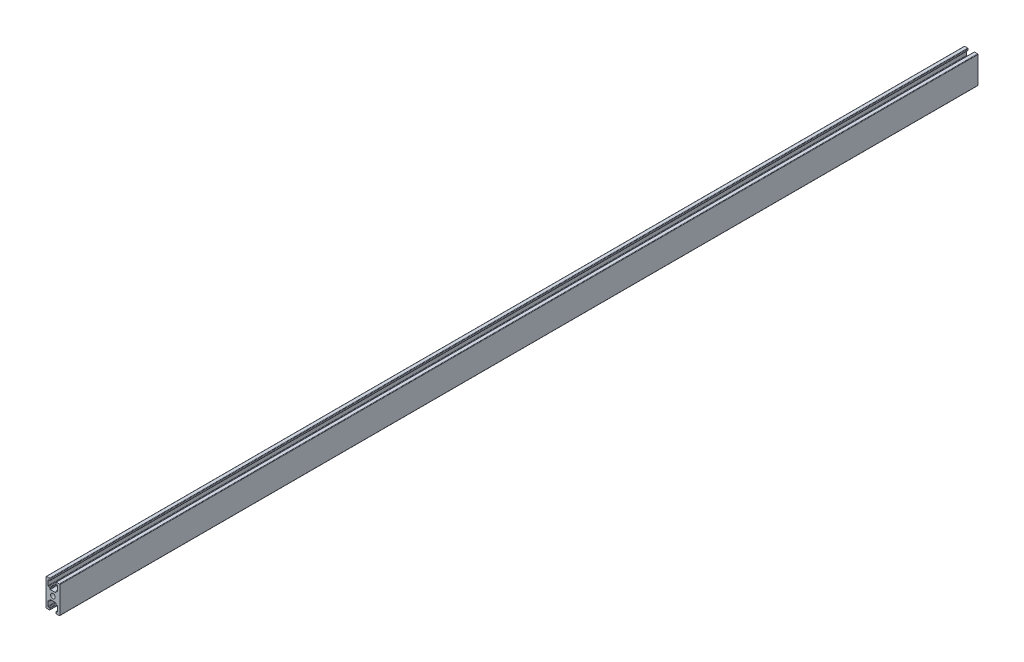
from build123d import *

# Parameters (mm, degrees)
SKETCH_2_R      = 2.5
EXTRUDE_1_DEPTH = 1000


with BuildPart() as part:
    # Эскиз2 → Бобышка-Вытянуть1 (new body)
    with BuildSketch(Plane.XY):
        with BuildLine():
            Line((-5.25, 15), (-7, 15))
            ThreePointArc((-7, 15), (-7.353553391, 14.853553391), (-7.5, 14.5))
            Line((-7.5, 14.5), (-7.5, -14.5))
            ThreePointArc((-7.5, -14.5), (-7.353553391, -14.853553391), (-7, -15))
            Line((-7, -15), (-5.25, -15))
            Line((-5.25, -15), (-3.75, -15))
            ThreePointArc((-3.75, -15), (-3.396446609, -14.853553391), (-3.25, -14.5))
            Line((-3.25, -14.5), (-3.25, -13.2))
            ThreePointArc((-3.25, -13.2), (-3.396446609, -12.846446609), (-3.75, -12.7))
            Line((-3.75, -12.7), (-4.75, -12.7))
            ThreePointArc((-4.75, -12.7), (-5.103553391, -12.553553391), (-5.25, -12.2))
            Line((-5.25, -12.2), (-5.25, -7.2))
            ThreePointArc((-5.25, -7.2), (-5.103553391, -6.846446609), (-4.75, -6.7))
            Line((-4.75, -6.7), (-3.75, -6.7))
            ThreePointArc((-3.75, -6.7), (-3.396446609, -6.553553391), (-3.25, -6.2))
            Line((-3.25, -6.2), (-3.25, -5.2))
            ThreePointArc((-3.25, -5.2), (-3.103553391, -4.846446609), (-2.75, -4.7))
            Line((-2.75, -4.7), (2.75, -4.7))
            ThreePointArc((2.75, -4.7), (3.103553391, -4.846446609), (3.25, -5.2))
            Line((3.25, -5.2), (3.25, -6.2))
            ThreePointArc((3.25, -6.2), (3.396446609, -6.553553391), (3.75, -6.7))
            Line((3.75, -6.7), (4.75, -6.7))
            ThreePointArc((4.75, -6.7), (5.103553391, -6.846446609), (5.25, -7.2))
            Line((5.25, -7.2), (5.25, -12.2))
            ThreePointArc((5.25, -12.2), (5.103553391, -12.553553391), (4.75, -12.7))
            Line((4.75, -12.7), (3.75, -12.7))
            ThreePointArc((3.75, -12.7), (3.396446609, -12.846446609), (3.25, -13.2))
            Line((3.25, -13.2), (3.25, -14.5))
            ThreePointArc((3.25, -14.5), (3.396446609, -14.853553391), (3.75, -15))
            Line((3.75, -15), (5.25, -15))
            Line((5.25, -15), (7, -15))
            ThreePointArc((7, -15), (7.353553391, -14.853553391), (7.5, -14.5))
            Line((7.5, -14.5), (7.5, 14.5))
            ThreePointArc((7.5, 14.5), (7.353553391, 14.853553391), (7, 15))
            Line((7, 15), (5.25, 15))
            Line((5.25, 15), (3.75, 15))
            ThreePointArc((3.75, 15), (3.396446609, 14.853553391), (3.25, 14.5))
            Line((3.25, 14.5), (3.25, 13.2))
            ThreePointArc((3.25, 13.2), (3.396446609, 12.846446609), (3.75, 12.7))
            Line((3.75, 12.7), (4.75, 12.7))
            ThreePointArc((4.75, 12.7), (5.103553391, 12.553553391), (5.25, 12.2))
            Line((5.25, 12.2), (5.25, 7.2))
            ThreePointArc((5.25, 7.2), (5.103553391, 6.846446609), (4.75, 6.7))
            Line((4.75, 6.7), (3.75, 6.7))
            ThreePointArc((3.75, 6.7), (3.396446609, 6.553553391), (3.25, 6.2))
            Line((3.25, 6.2), (3.25, 5.2))
            ThreePointArc((3.25, 5.2), (3.103553391, 4.846446609), (2.75, 4.7))
            Line((2.75, 4.7), (-2.75, 4.7))
            ThreePointArc((-2.75, 4.7), (-3.103553391, 4.846446609), (-3.25, 5.2))
            Line((-3.25, 5.2), (-3.25, 6.2))
            ThreePointArc((-3.25, 6.2), (-3.396446609, 6.553553391), (-3.75, 6.7))
            Line((-3.75, 6.7), (-4.75, 6.7))
            ThreePointArc((-4.75, 6.7), (-5.103553391, 6.846446609), (-5.25, 7.2))
            Line((-5.25, 7.2), (-5.25, 12.2))
            ThreePointArc((-5.25, 12.2), (-5.103553391, 12.553553391), (-4.75, 12.7))
            Line((-4.75, 12.7), (-3.75, 12.7))
            ThreePointArc((-3.75, 12.7), (-3.396446609, 12.846446609), (-3.25, 13.2))
            Line((-3.25, 13.2), (-3.25, 14.5))
            ThreePointArc((-3.25, 14.5), (-3.396446609, 14.853553391), (-3.75, 15))
            Line((-3.75, 15), (-5.25, 15))
        make_face()
        Circle(SKETCH_2_R, mode=Mode.SUBTRACT)
    extrude(amount=EXTRUDE_1_DEPTH)


solid = part.part
